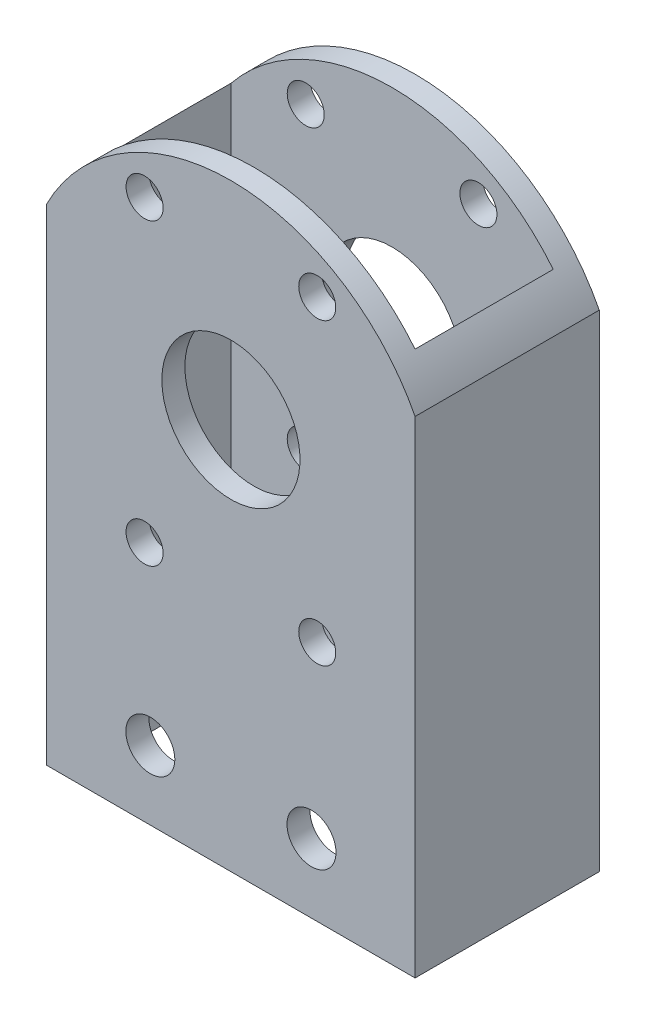
from build123d import *

# Parameters (mm, degrees)
SKETCH1_W               = 50.8
SKETCH1_H               = 25.4
SKETCH1_W_2             = 44.45
SKETCH1_H_2             = 19.05
EXTRUDE_THIN1_DEPTH     = 82.55
F_10_CLEARANCE_HOLE1_D  = 5.1054
SKETCH7_R               = 9.525
CUT_EXTRUDE2_DEPTH      = 1
CUT_EXTRUDE2_DEPTH_BACK = 26.4
F_1_4_CLEARANCE_HOLE2_D = 6.7564
CUT_EXTRUDE3_DEPTH      = 26.4


with BuildPart() as part:
    # Sketch1 → Extrude-Thin1 (new body)
    with BuildSketch(Plane(origin=(0, 0, 0), x_dir=(1, 0, 0), z_dir=(0, 1, 0))):
        Rectangle(SKETCH1_W, SKETCH1_H)
        Rectangle(SKETCH1_W_2, SKETCH1_H_2, mode=Mode.SUBTRACT)
    extrude(amount=EXTRUDE_THIN1_DEPTH)

    # #10 Clearance Hole1 (through all)
    with Locations(Plane(origin=(0, 0, -12.7), x_dir=(-1, 0, 0), z_dir=(0, 0, -1))):
        with Locations((-11.90625, 33.352770072), (-11.90625, 74.597229928), (11.90625, 74.597229928), (11.90625, 33.352770072)):
            Hole(F_10_CLEARANCE_HOLE1_D / 2)

    # Sketch7 → Cut-Extrude2 (cut, two sides)
    with BuildSketch(Plane(origin=(0, 0, -12.7), x_dir=(-1, 0, 0), z_dir=(0, 0, -1))) as cut_extrude2_sk:
        with Locations((0, 53.975)):
            Circle(SKETCH7_R)
    extrude(amount=CUT_EXTRUDE2_DEPTH, mode=Mode.SUBTRACT)
    extrude(cut_extrude2_sk.sketch, amount=-CUT_EXTRUDE2_DEPTH_BACK, mode=Mode.SUBTRACT)

    # 1/4 Clearance Hole2 (through all)
    with Locations(Plane.XY.offset(12.7)):
        with Locations((-11.1125, 9.525), (11.1125, 9.525), (-109.171479686, 68.785430569)):
            Hole(F_1_4_CLEARANCE_HOLE2_D / 2)

    # Sketch10 → Cut-Extrude3 (cut, through all)
    with BuildSketch(Plane(origin=(0, 0, -12.7), x_dir=(-1, 0, 0), z_dir=(0, 0, -1))):
        with BuildLine():
            Line((-25.4, 82.55), (-25.4, 67.065860361))
            ThreePointArc((-25.4, 67.065860361), (-14.873790542, 78.373790542), (0, 82.55))
            Line((0, 82.55), (-25.4, 82.55))
        make_face()
        with BuildLine():
            Line((25.4, 82.55), (0, 82.55))
            ThreePointArc((0, 82.55), (14.873790542, 78.373790542), (25.4, 67.065860361))
            Line((25.4, 67.065860361), (25.4, 82.55))
        make_face()
    extrude(amount=-CUT_EXTRUDE3_DEPTH, mode=Mode.SUBTRACT)


solid = part.part
